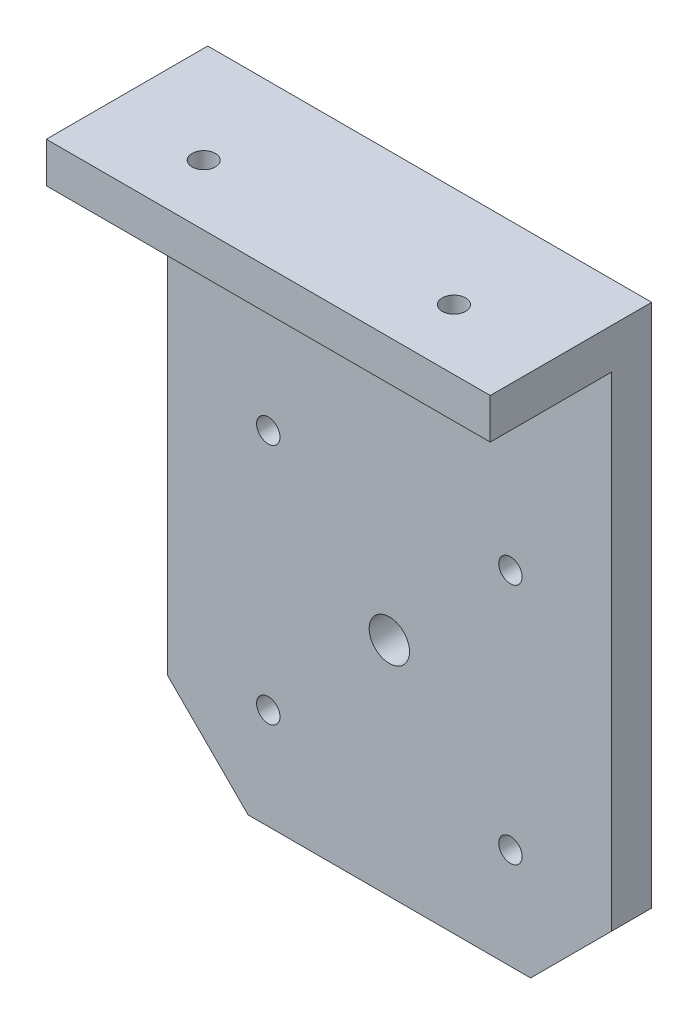
from build123d import *

# Parameters (mm, degrees)
BOSS_EXTRUDE1_DEPTH                               = 5
CUT_EXTRUDE1_REACH                                = 7
SKETCH2_R                                         = 2.5
SKETCH3_W                                         = 55
SKETCH3_H                                         = 5
BOSS_EXTRUDE2_DEPTH                               = 15
CSK_FOR_M2_5_FLAT_HEAD_MACHINE_SCREW1_D           = 2.9
CSK_FOR_M2_5_FLAT_HEAD_MACHINE_SCREW1_CSINK_D     = 5.5
CSK_FOR_M2_5_FLAT_HEAD_MACHINE_SCREW1_CSINK_ANGLE = 90
CSK_FOR_M2_5_FLAT_HEAD_MACHINE_SCREW2_D           = 2.9
CSK_FOR_M2_5_FLAT_HEAD_MACHINE_SCREW2_DEPTH       = 5
CSK_FOR_M2_5_FLAT_HEAD_MACHINE_SCREW2_CSINK_D     = 5.5
CSK_FOR_M2_5_FLAT_HEAD_MACHINE_SCREW2_CSINK_ANGLE = 90


with BuildPart() as part:
    # Sketch1 → Boss-Extrude1 (new body)
    with BuildSketch(Plane.XY):
        Polygon((-17.5, -37.5), (-27.5, -27.5), (-27.5, 37.5), (27.5, 37.5), (27.5, -27.5), (17.5, -37.5), align=None)
    extrude(amount=BOSS_EXTRUDE1_DEPTH)

    # Sketch2 → Cut-Extrude1 (cut, up to next)
    with BuildSketch(Plane.XY.offset(5), mode=Mode.PRIVATE) as cut_extrude1_sk1:
        with Locations((0, -10)):
            Circle(SKETCH2_R)
    cut_extrude1_tool1 = extrude(cut_extrude1_sk1.sketch, amount=-CUT_EXTRUDE1_REACH, mode=Mode.PRIVATE) & part.part
    add(cut_extrude1_tool1.solids().sort_by_distance((0, -10, 5))[0], mode=Mode.SUBTRACT)

    # Sketch3 → Boss-Extrude2 (add)
    with BuildSketch(Plane.XY.offset(5)):
        with Locations((0, 35)):
            Rectangle(SKETCH3_W, SKETCH3_H)
    extrude(amount=BOSS_EXTRUDE2_DEPTH)

    # CSK for M2.5 Flat Head Machine Screw1 (through all)
    with Locations(Plane(origin=(0, 32.5, 0), x_dir=(-1, 0, 0), z_dir=(0, -1, 0))):
        with Locations((-15.5, -12.5), (15.5, -12.5)):
            CounterSinkHole(CSK_FOR_M2_5_FLAT_HEAD_MACHINE_SCREW1_D / 2, CSK_FOR_M2_5_FLAT_HEAD_MACHINE_SCREW1_CSINK_D / 2, counter_sink_angle=CSK_FOR_M2_5_FLAT_HEAD_MACHINE_SCREW1_CSINK_ANGLE)

    # CSK for M2.5 Flat Head Machine Screw2
    with Locations(Plane(origin=(0, 0, 0), x_dir=(-1, 0, 0), z_dir=(0, 0, -1))):
        with Locations((-15, 5), (15, 5), (-15, -25), (15, -25)):
            CounterSinkHole(CSK_FOR_M2_5_FLAT_HEAD_MACHINE_SCREW2_D / 2, CSK_FOR_M2_5_FLAT_HEAD_MACHINE_SCREW2_CSINK_D / 2, depth=CSK_FOR_M2_5_FLAT_HEAD_MACHINE_SCREW2_DEPTH, counter_sink_angle=CSK_FOR_M2_5_FLAT_HEAD_MACHINE_SCREW2_CSINK_ANGLE)


solid = part.part
